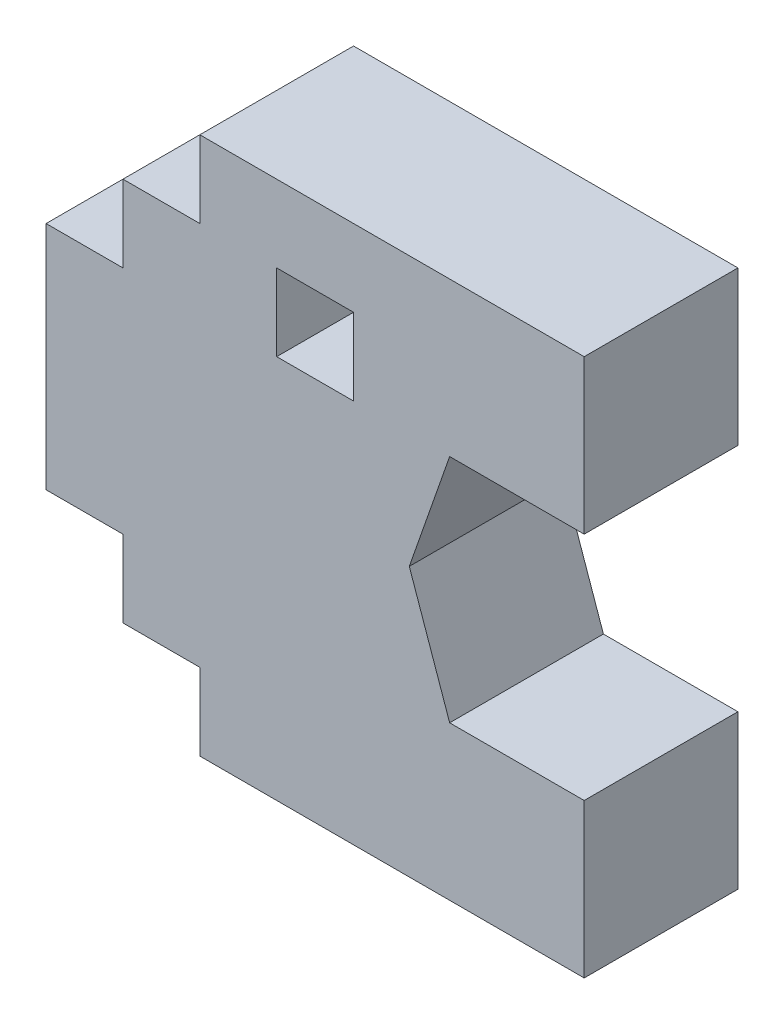
from build123d import *

# Parameters (mm, degrees)
SKETCH1_W      = 20
SKETCH1_H      = 20
EXTRUDE1_DEPTH = 40


with BuildPart() as part:
    # Sketch1 → Extrude1 (new body)
    with BuildSketch(Plane.XY):
        Polygon((0, 140), (100, 140), (100, 100), (65, 100), (54.5, 70), (65, 40), (100, 40), (100, 0), (0, 0), (0, 20), (-20, 20), (-20, 40), (-40, 40), (-40, 100), (-20, 100), (-20, 120), (0, 120), align=None)
        with Locations((30, 110)):
            Rectangle(SKETCH1_W, SKETCH1_H, mode=Mode.SUBTRACT)
    extrude(amount=EXTRUDE1_DEPTH)


solid = part.part
